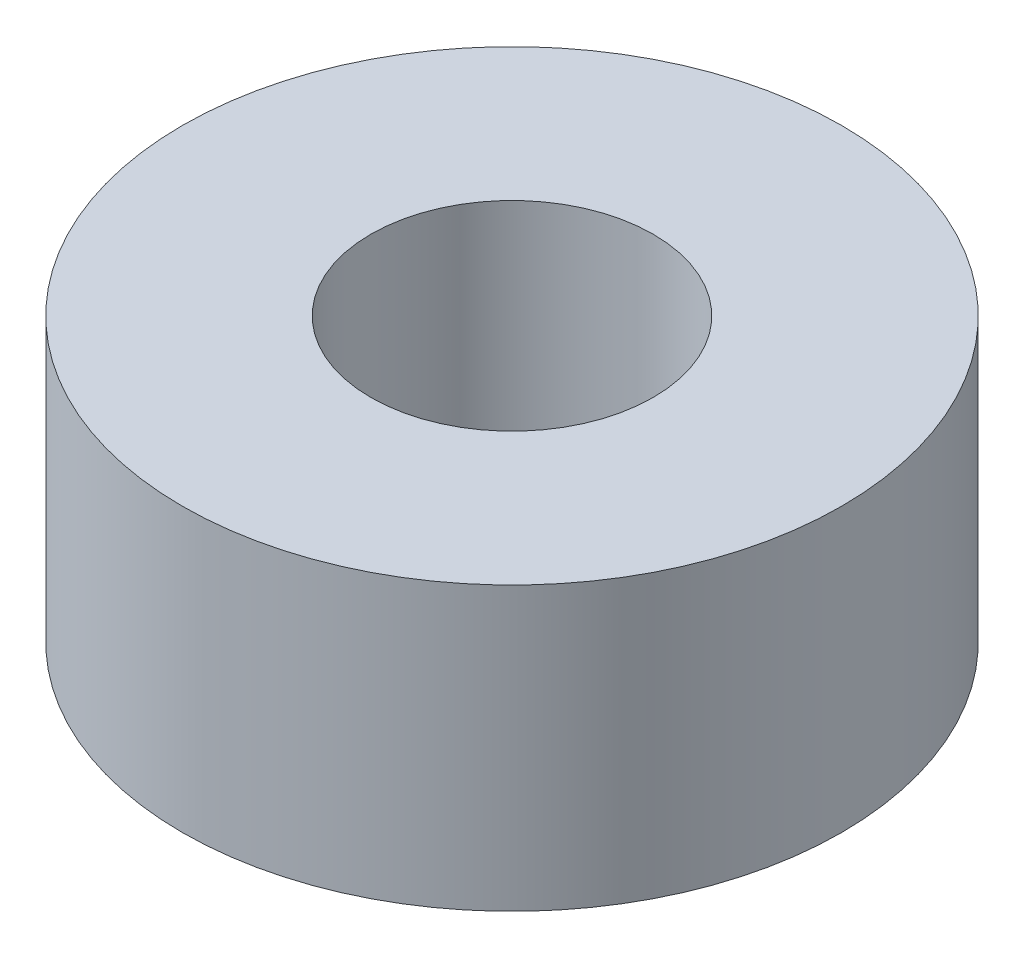
from build123d import *

# Parameters (mm, degrees)
SKETCH1_R           = 3.5
SKETCH1_R_2         = 1.5
BOSS_EXTRUDE1_DEPTH = 3


with BuildPart() as part:
    # Sketch1 → Boss-Extrude1 (new body)
    with BuildSketch(Plane(origin=(0, 0, 0), x_dir=(1, 0, 0), z_dir=(0, 1, 0))):
        with Locations(Location((0, 0, 0), (0, 0, 270))):  # turned: the seam where the file's is
            Circle(SKETCH1_R)
        with Locations(Location((0, 0, 0), (0, 0, 270))):  # turned: the seam where the file's is
            Circle(SKETCH1_R_2, mode=Mode.SUBTRACT)
    extrude(amount=BOSS_EXTRUDE1_DEPTH)


solid = part.part
